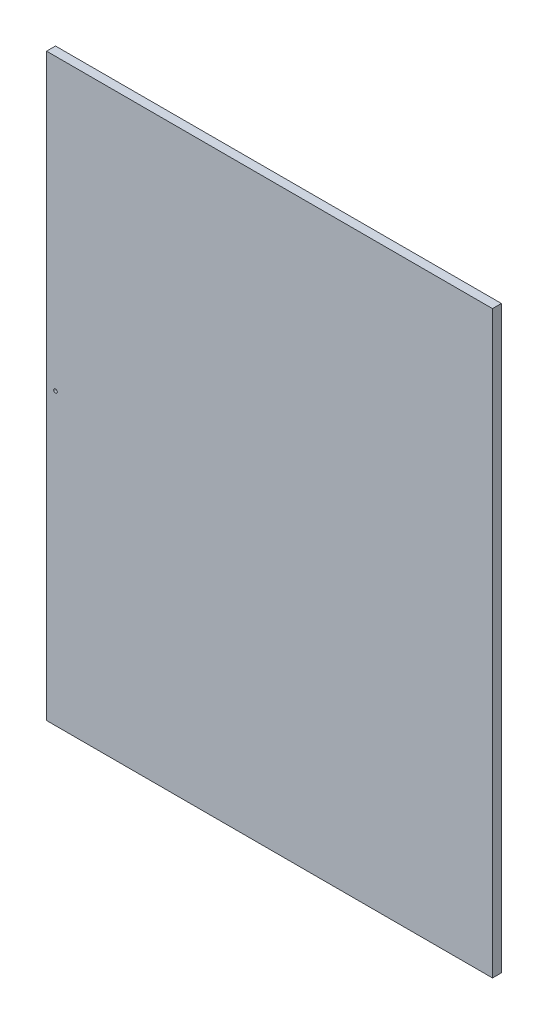
from build123d import *

# Parameters (mm, degrees)
SKETCH_1_W      = 500
SKETCH_1_H      = 650
SKETCH_1_R      = 2
EXTRUDE_1_DEPTH = 10


with BuildPart() as part:
    # 草图1 → 凸台-拉伸1 (new body)
    with BuildSketch(Plane.XY):
        with Locations((250, 325)):
            Rectangle(SKETCH_1_W, SKETCH_1_H)
        with Locations((10, 325)):
            Circle(SKETCH_1_R, mode=Mode.SUBTRACT)
    extrude(amount=EXTRUDE_1_DEPTH)


solid = part.part
